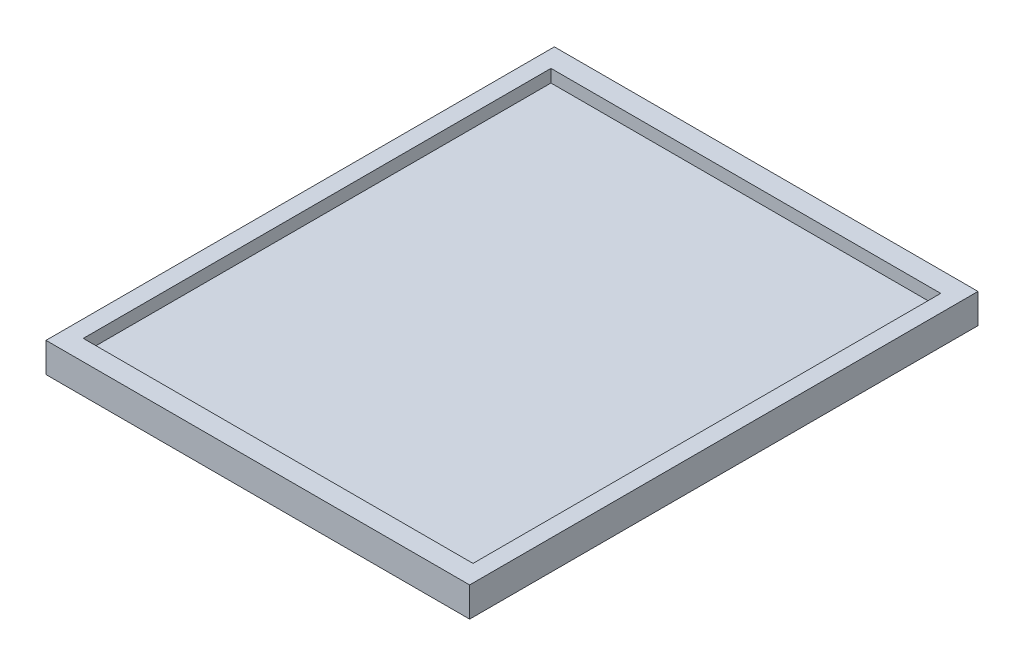
from build123d import *

# Parameters (mm, degrees)
ESBO_O1_W                = 100
ESBO_O1_H                = 120
RESSALTO_EXTRUS_O1_DEPTH = 4
ESBO_O3_W                = 100
ESBO_O3_H                = 120
ESBO_O3_W_2              = 92
ESBO_O3_H_2              = 110.4
RESSALTO_EXTRUS_O2_DEPTH = 7


with BuildPart() as part:
    # Esboço1 → Ressalto-extrusão1 (new body)
    with BuildSketch(Plane(origin=(0, 0, 0), x_dir=(1, 0, 0), z_dir=(0, 1, 0))):
        with Locations((50, 60)):
            Rectangle(ESBO_O1_W, ESBO_O1_H)
    extrude(amount=RESSALTO_EXTRUS_O1_DEPTH)

    # Esboço3 → Ressalto-extrusão2 (add)
    with BuildSketch(Plane(origin=(0, 0, 0), x_dir=(1, 0, 0), z_dir=(0, 1, 0))):
        with Locations((50, 60)):
            Rectangle(ESBO_O3_W, ESBO_O3_H)
        with Locations((50, 60)):
            Rectangle(ESBO_O3_W_2, ESBO_O3_H_2, mode=Mode.SUBTRACT)
    extrude(amount=RESSALTO_EXTRUS_O2_DEPTH)


solid = part.part
